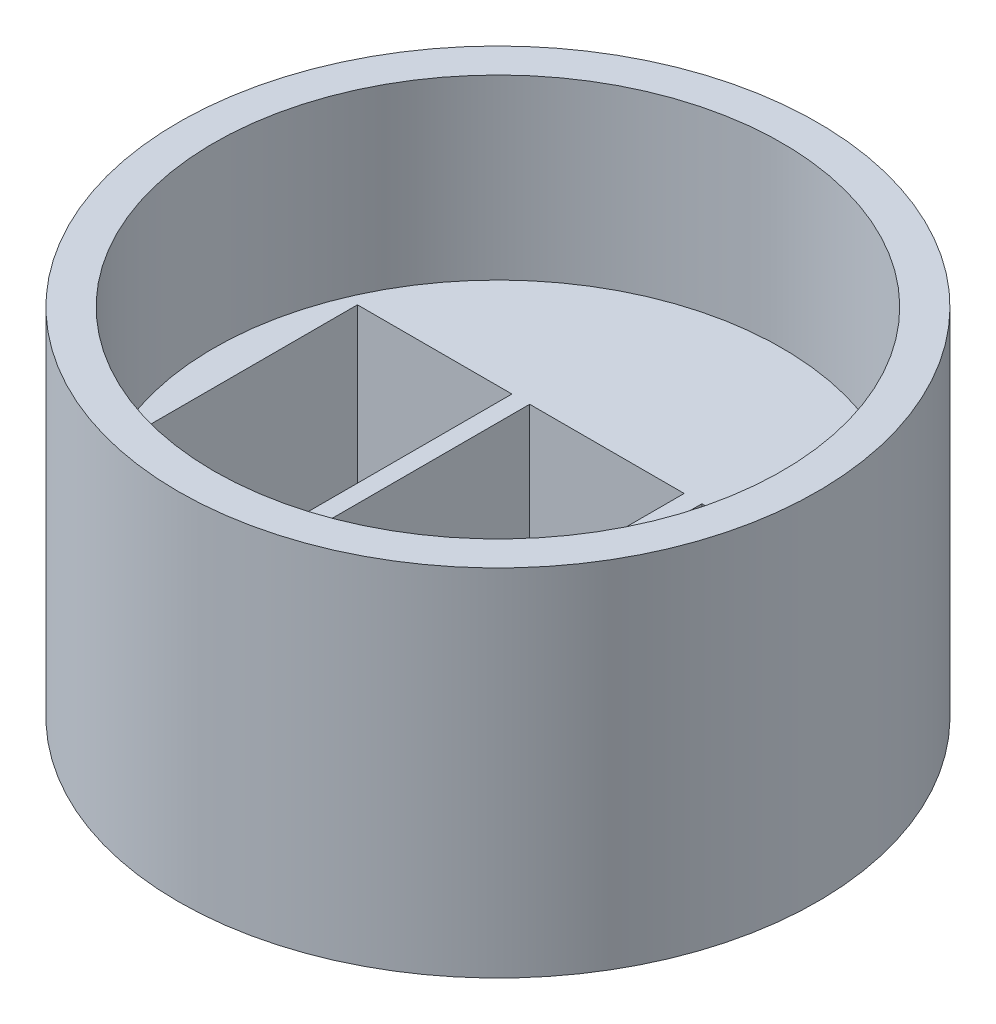
from build123d import *

# Parameters (mm, degrees)
SKETCH2_R           = 9
BOSS_EXTRUDE2_DEPTH = 10
SKETCH3_R           = 8
CUT_EXTRUDE1_DEPTH  = 5
SKETCH4_W           = 4.35
SKETCH4_H           = 6.15
CUT_EXTRUDE2_DEPTH  = 6


with BuildPart() as part:
    # Sketch2 → Boss-Extrude2 (new body)
    with BuildSketch(Plane(origin=(0, 0, 0), x_dir=(1, 0, 0), z_dir=(0, 1, 0))):
        Circle(SKETCH2_R)
    extrude(amount=BOSS_EXTRUDE2_DEPTH)

    # Sketch3 → Cut-Extrude1 (cut)
    with BuildSketch(Plane(origin=(0, 10, 0), x_dir=(1, 0, 0), z_dir=(0, 1, 0))):
        Circle(SKETCH3_R)
    extrude(amount=-CUT_EXTRUDE1_DEPTH, mode=Mode.SUBTRACT)

    # Sketch4 → Cut-Extrude2 (cut, through all)
    with BuildSketch(Plane(origin=(0, 5, 0), x_dir=(1, 0, 0), z_dir=(0, 1, 0))):
        with Locations((-0.006105592, 0)):
            Rectangle(SKETCH4_W, SKETCH4_H)
        with Locations((-4.856105592, 0)):
            Rectangle(SKETCH4_W, SKETCH4_H)
        with Locations((4.843894408, 0)):
            Rectangle(SKETCH4_W, SKETCH4_H)
    extrude(amount=-CUT_EXTRUDE2_DEPTH, mode=Mode.SUBTRACT)


solid = part.part
